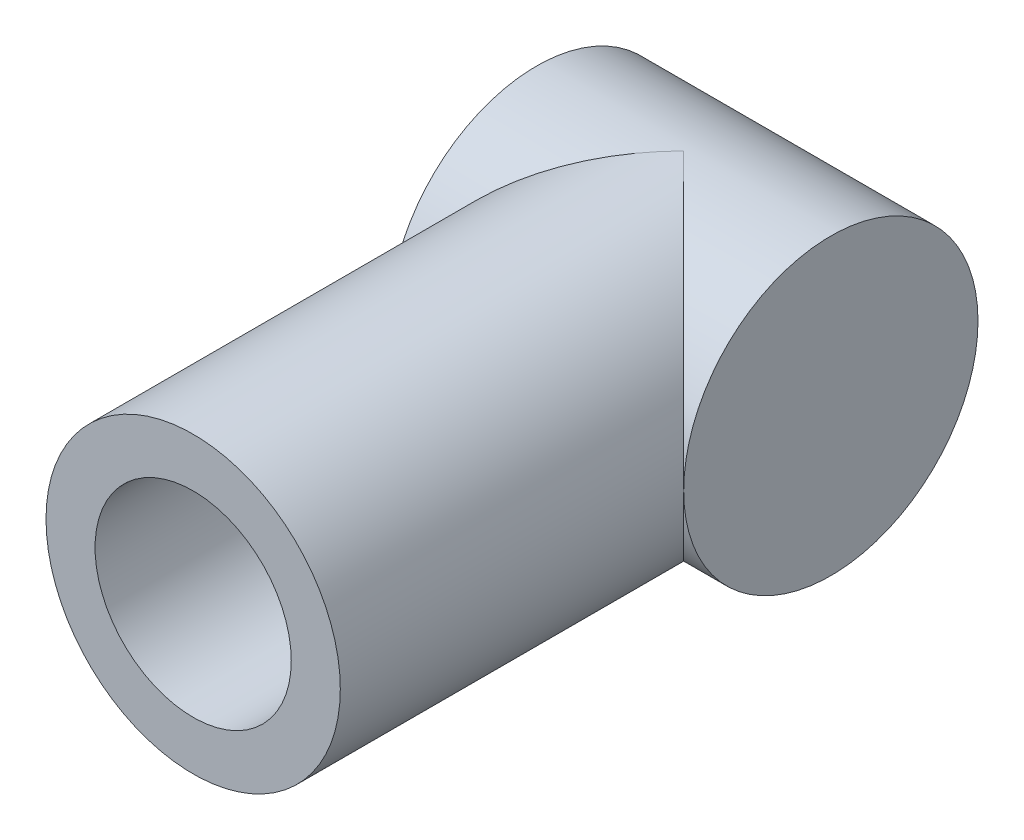
from build123d import *

# Parameters (mm, degrees)
SKETCH1_R           = 75
BOSS_EXTRUDE1_DEPTH = 75
SKETCH2_R           = 75
BOSS_EXTRUDE2_DEPTH = 250
SKETCH3_R           = 50
CUT_EXTRUDE1_DEPTH  = 150


with BuildPart() as part:
    # Sketch1 → Boss-Extrude1 (new body, symmetric)
    with BuildSketch(Plane(origin=(0, 0, 0), x_dir=(0, 0, -1), z_dir=(1, 0, 0))):
        Circle(SKETCH1_R)
    extrude(amount=BOSS_EXTRUDE1_DEPTH, both=True)

    # Sketch2 → Boss-Extrude2 (add)
    with BuildSketch(Plane.XY):
        Circle(SKETCH2_R)
    extrude(amount=BOSS_EXTRUDE2_DEPTH)

    # Sketch3 → Cut-Extrude1 (cut)
    with BuildSketch(Plane.XY.offset(250)):
        Circle(SKETCH3_R)
    extrude(amount=-CUT_EXTRUDE1_DEPTH, mode=Mode.SUBTRACT)


solid = part.part
